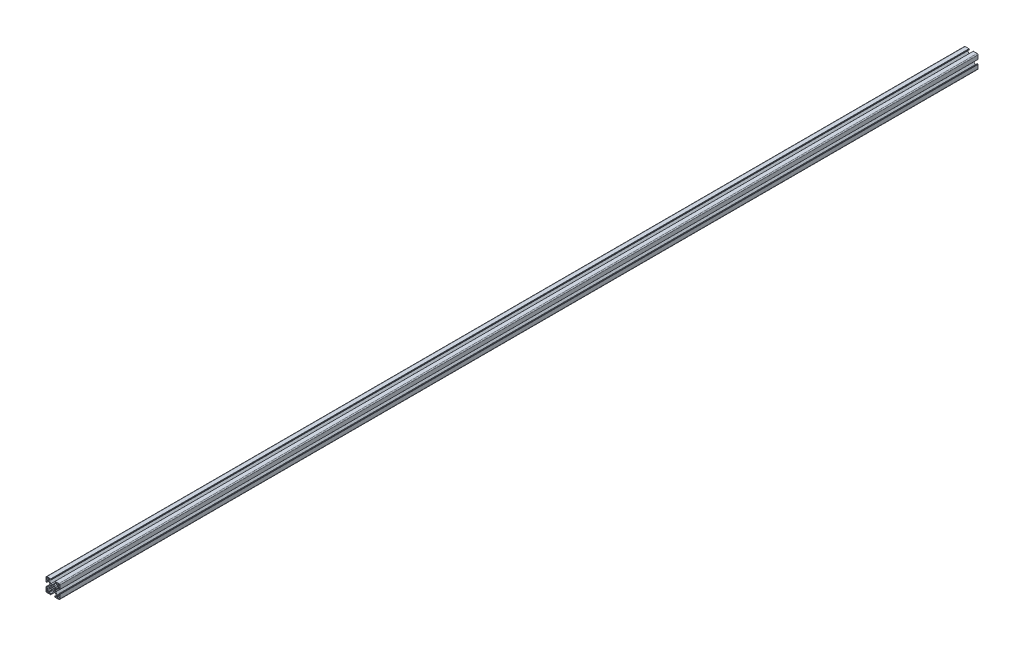
from build123d import *

# Parameters (mm, degrees)
SIGMA_PROFILE_DEPTH = 2000


with BuildPart() as part:
    # Sketch1 → Sigma Profile (new body)
    with BuildSketch(Plane.XY):
        with BuildLine():
            Line((96.56, 29.575148163), (97.459999946, 29.06))
            Line((97.459999946, 29.06), (100.764466193, 29.06))
            Line((100.764466193, 29.06), (104.810000327, 25.010000763))
            Line((104.810000327, 25.010000763), (104.810000327, 22.460001166))
            ThreePointArc((104.810000327, 22.460001166), (104.751421565, 22.318579525), (104.609999924, 22.260000763))
            Line((104.609999924, 22.260000763), (101.210000197, 22.260000763))
            ThreePointArc((101.210000197, 22.260000763), (100.785735989, 22.084264774), (100.61, 21.660000566))
            Line((100.61, 21.660000566), (100.61, 20.760000374))
            ThreePointArc((100.61, 20.760000374), (100.668578753, 20.618578753), (100.810000374, 20.56))
            Line((100.810000374, 20.56), (100.910000144, 20.56))
            ThreePointArc((100.910000144, 20.56), (101.05142109, 20.501421526), (101.109999564, 20.36000058))
            Line((101.109999564, 20.36000058), (101.109999564, 20.260000381))
            ThreePointArc((101.109999564, 20.260000381), (101.16857832, 20.118578755), (101.309999945, 20.06))
            Line((101.309999945, 20.06), (109.560000346, 20.06))
            ThreePointArc((109.560000346, 20.06), (110.974213664, 20.645786336), (111.56, 22.059999654))
            Line((111.56, 22.059999654), (111.56, 30.310000479))
            ThreePointArc((111.56, 30.310000479), (111.501421273, 30.451422036), (111.359999716, 30.510000763))
            Line((111.359999716, 30.510000763), (111.260000611, 30.510000763))
            ThreePointArc((111.260000611, 30.510000763), (111.118579054, 30.56857949), (111.060000327, 30.710001047))
            Line((111.060000327, 30.710001047), (111.060000327, 30.810000479))
            ThreePointArc((111.060000327, 30.810000479), (111.0014216, 30.951422036), (110.860000043, 31.010000763))
            Line((110.860000043, 31.010000763), (109.95999994, 31.010000763))
            ThreePointArc((109.95999994, 31.010000763), (109.535735606, 30.834264722), (109.359999564, 30.410000387))
            Line((109.359999564, 30.410000387), (109.359999564, 27.010000284))
            ThreePointArc((109.359999564, 27.010000284), (109.301420837, 26.868578727), (109.15999928, 26.81))
            Line((109.15999928, 26.81), (106.609999564, 26.81))
            Line((106.609999564, 26.81), (102.56446543, 30.855534134))
            Line((102.56446543, 30.855534134), (102.56446543, 34.160000381))
            Line((102.56446543, 34.160000381), (102.044852164, 35.06))
            Line((102.044852164, 35.06), (102.56446543, 35.959999619))
            Line((102.56446543, 35.959999619), (102.56446543, 39.264465866))
            Line((102.56446543, 39.264465866), (106.609999564, 43.31))
            Line((106.609999564, 43.31), (109.15999928, 43.31))
            ThreePointArc((109.15999928, 43.31), (109.301420837, 43.251421273), (109.359999564, 43.109999716))
            Line((109.359999564, 43.109999716), (109.359999564, 39.709999613))
            ThreePointArc((109.359999564, 39.709999613), (109.535735606, 39.285735278), (109.95999994, 39.109999237))
            Line((109.95999994, 39.109999237), (110.860000043, 39.109999237))
            ThreePointArc((110.860000043, 39.109999237), (111.0014216, 39.168577964), (111.060000327, 39.309999521))
            Line((111.060000327, 39.309999521), (111.060000327, 39.409998953))
            ThreePointArc((111.060000327, 39.409998953), (111.118579054, 39.55142051), (111.260000611, 39.609999237))
            Line((111.260000611, 39.609999237), (111.359999716, 39.609999237))
            ThreePointArc((111.359999716, 39.609999237), (111.501421273, 39.668577964), (111.56, 39.809999521))
            Line((111.56, 39.809999521), (111.56, 48.060000346))
            ThreePointArc((111.56, 48.060000346), (110.974213664, 49.474213664), (109.560000346, 50.06))
            Line((109.560000346, 50.06), (101.309999945, 50.06))
            ThreePointArc((101.309999945, 50.06), (101.16857832, 50.001421245), (101.109999564, 49.859999619))
            Line((101.109999564, 49.859999619), (101.109999564, 49.75999942))
            ThreePointArc((101.109999564, 49.75999942), (101.05142109, 49.618578474), (100.910000144, 49.56))
            Line((100.910000144, 49.56), (100.810000374, 49.56))
            ThreePointArc((100.810000374, 49.56), (100.668578753, 49.501421247), (100.61, 49.359999626))
            Line((100.61, 49.359999626), (100.61, 48.459999434))
            ThreePointArc((100.61, 48.459999434), (100.785735989, 48.035735226), (101.210000197, 47.859999237))
            Line((101.210000197, 47.859999237), (104.609999924, 47.859999237))
            ThreePointArc((104.609999924, 47.859999237), (104.751421565, 47.801420475), (104.810000327, 47.659998834))
            Line((104.810000327, 47.659998834), (104.810000327, 45.109999237))
            Line((104.810000327, 45.109999237), (100.764466193, 41.06))
            Line((100.764466193, 41.06), (97.459999946, 41.06))
            Line((97.459999946, 41.06), (96.56, 40.544851837))
            Line((96.56, 40.544851837), (95.660000054, 41.06))
            Line((95.660000054, 41.06), (92.355533807, 41.06))
            Line((92.355533807, 41.06), (88.309999673, 45.109999237))
            Line((88.309999673, 45.109999237), (88.309999673, 47.659998834))
            ThreePointArc((88.309999673, 47.659998834), (88.368578435, 47.801420475), (88.510000076, 47.859999237))
            Line((88.510000076, 47.859999237), (91.909999803, 47.859999237))
            ThreePointArc((91.909999803, 47.859999237), (92.334264011, 48.035735226), (92.51, 48.459999434))
            Line((92.51, 48.459999434), (92.51, 49.359999626))
            ThreePointArc((92.51, 49.359999626), (92.451421247, 49.501421247), (92.309999626, 49.56))
            Line((92.309999626, 49.56), (92.209999856, 49.56))
            ThreePointArc((92.209999856, 49.56), (92.06857891, 49.618578474), (92.010000436, 49.75999942))
            Line((92.010000436, 49.75999942), (92.010000436, 49.859999619))
            ThreePointArc((92.010000436, 49.859999619), (91.95142168, 50.001421245), (91.810000055, 50.06))
            Line((91.810000055, 50.06), (83.559999654, 50.06))
            ThreePointArc((83.559999654, 50.06), (82.145786336, 49.474213664), (81.56, 48.060000346))
            Line((81.56, 48.060000346), (81.56, 39.809999521))
            ThreePointArc((81.56, 39.809999521), (81.618578727, 39.668577964), (81.760000284, 39.609999237))
            Line((81.760000284, 39.609999237), (81.859999389, 39.609999237))
            ThreePointArc((81.859999389, 39.609999237), (82.001420946, 39.55142051), (82.059999673, 39.409998953))
            Line((82.059999673, 39.409998953), (82.059999673, 39.309999521))
            ThreePointArc((82.059999673, 39.309999521), (82.1185784, 39.168577964), (82.259999957, 39.109999237))
            Line((82.259999957, 39.109999237), (83.16000006, 39.109999237))
            ThreePointArc((83.16000006, 39.109999237), (83.584264394, 39.285735278), (83.760000436, 39.709999613))
            Line((83.760000436, 39.709999613), (83.760000436, 43.109999716))
            ThreePointArc((83.760000436, 43.109999716), (83.818579163, 43.251421273), (83.96000072, 43.31))
            Line((83.96000072, 43.31), (86.510000436, 43.31))
            Line((86.510000436, 43.31), (90.55553457, 39.264465866))
            Line((90.55553457, 39.264465866), (90.55553457, 35.959999619))
            Line((90.55553457, 35.959999619), (91.075147836, 35.06))
            Line((91.075147836, 35.06), (90.55553457, 34.160000381))
            Line((90.55553457, 34.160000381), (90.55553457, 30.855534134))
            Line((90.55553457, 30.855534134), (86.510000436, 26.81))
            Line((86.510000436, 26.81), (83.96000072, 26.81))
            ThreePointArc((83.96000072, 26.81), (83.818579163, 26.868578727), (83.760000436, 27.010000284))
            Line((83.760000436, 27.010000284), (83.760000436, 30.410000387))
            ThreePointArc((83.760000436, 30.410000387), (83.584264394, 30.834264722), (83.16000006, 31.010000763))
            Line((83.16000006, 31.010000763), (82.259999957, 31.010000763))
            ThreePointArc((82.259999957, 31.010000763), (82.1185784, 30.951422036), (82.059999673, 30.810000479))
            Line((82.059999673, 30.810000479), (82.059999673, 30.710001047))
            ThreePointArc((82.059999673, 30.710001047), (82.001420946, 30.56857949), (81.859999389, 30.510000763))
            Line((81.859999389, 30.510000763), (81.760000284, 30.510000763))
            ThreePointArc((81.760000284, 30.510000763), (81.618578727, 30.451422036), (81.56, 30.310000479))
            Line((81.56, 30.310000479), (81.56, 22.059999654))
            ThreePointArc((81.56, 22.059999654), (82.145786336, 20.645786336), (83.559999654, 20.06))
            Line((83.559999654, 20.06), (91.810000055, 20.06))
            ThreePointArc((91.810000055, 20.06), (91.95142168, 20.118578755), (92.010000436, 20.260000381))
            Line((92.010000436, 20.260000381), (92.010000436, 20.36000058))
            ThreePointArc((92.010000436, 20.36000058), (92.06857891, 20.501421526), (92.209999856, 20.56))
            Line((92.209999856, 20.56), (92.309999626, 20.56))
            ThreePointArc((92.309999626, 20.56), (92.451421247, 20.618578753), (92.51, 20.760000374))
            Line((92.51, 20.760000374), (92.51, 21.660000566))
            ThreePointArc((92.51, 21.660000566), (92.334264011, 22.084264774), (91.909999803, 22.260000763))
            Line((91.909999803, 22.260000763), (88.510000076, 22.260000763))
            ThreePointArc((88.510000076, 22.260000763), (88.368578435, 22.318579525), (88.309999673, 22.460001166))
            Line((88.309999673, 22.460001166), (88.309999673, 25.010000763))
            Line((88.309999673, 25.010000763), (92.355533807, 29.06))
            Line((92.355533807, 29.06), (95.660000054, 29.06))
            Line((95.660000054, 29.06), (96.56, 29.575148163))
        make_face()
        with BuildLine():
            Line((109.26000109, 48.760000398), (107.060000327, 48.760000398))
            ThreePointArc((107.060000327, 48.760000398), (106.352893543, 48.467107182), (106.060000327, 47.760000398))
            Line((106.060000327, 47.760000398), (106.060000327, 45.559999635))
            ThreePointArc((106.060000327, 45.559999635), (106.352893543, 44.852892851), (107.060000327, 44.559999635))
            Line((107.060000327, 44.559999635), (109.26000109, 44.559999635))
            ThreePointArc((109.26000109, 44.559999635), (109.967107874, 44.852892851), (110.26000109, 45.559999635))
            Line((110.26000109, 45.559999635), (110.26000109, 47.760000398))
            ThreePointArc((110.26000109, 47.760000398), (109.967107874, 48.467107182), (109.26000109, 48.760000398))
        make_face(mode=Mode.SUBTRACT)
        with BuildLine():
            Line((94.959870476, 38.340561767), (93.424070588, 39.578400903))
            ThreePointArc((93.424070588, 39.578400903), (92.678997741, 38.957155561), (92.054663108, 38.214669473))
            Line((92.054663108, 38.214669473), (93.279438268, 36.660129597))
            ThreePointArc((93.279438268, 36.660129597), (92.91, 35.06), (93.279438268, 33.459870403))
            Line((93.279438268, 33.459870403), (92.054663108, 31.905330527))
            ThreePointArc((92.054663108, 31.905330527), (92.678997741, 31.162844439), (93.424070588, 30.541599097))
            Line((93.424070588, 30.541599097), (94.959870476, 31.779438233))
            ThreePointArc((94.959870476, 31.779438233), (96.56, 31.41), (98.160129524, 31.779438233))
            Line((98.160129524, 31.779438233), (99.695929412, 30.541599097))
            ThreePointArc((99.695929412, 30.541599097), (100.441002259, 31.162844439), (101.065336892, 31.905330527))
            Line((101.065336892, 31.905330527), (99.840561732, 33.459870403))
            ThreePointArc((99.840561732, 33.459870403), (100.21, 35.06), (99.840561732, 36.660129597))
            Line((99.840561732, 36.660129597), (101.065336892, 38.214669473))
            ThreePointArc((101.065336892, 38.214669473), (100.441002259, 38.957155561), (99.695929412, 39.578400903))
            Line((99.695929412, 39.578400903), (98.160129524, 38.340561767))
            ThreePointArc((98.160129524, 38.340561767), (96.56, 38.71), (94.959870476, 38.340561767))
        make_face(mode=Mode.SUBTRACT)
        with BuildLine():
            Line((83.85999891, 21.359999602), (86.059999673, 21.359999602))
            ThreePointArc((86.059999673, 21.359999602), (86.767106457, 21.652892818), (87.059999673, 22.359999602))
            Line((87.059999673, 22.359999602), (87.059999673, 24.560000365))
            ThreePointArc((87.059999673, 24.560000365), (86.767106457, 25.267107149), (86.059999673, 25.560000365))
            Line((86.059999673, 25.560000365), (83.85999891, 25.560000365))
            ThreePointArc((83.85999891, 25.560000365), (83.152892126, 25.267107149), (82.85999891, 24.560000365))
            Line((82.85999891, 24.560000365), (82.85999891, 22.359999602))
            ThreePointArc((82.85999891, 22.359999602), (83.152892126, 21.652892818), (83.85999891, 21.359999602))
        make_face(mode=Mode.SUBTRACT)
        with BuildLine():
            Line((110.26000109, 22.359999602), (110.26000109, 24.560000365))
            ThreePointArc((110.26000109, 24.560000365), (109.967107874, 25.267107149), (109.26000109, 25.560000365))
            Line((109.26000109, 25.560000365), (107.060000327, 25.560000365))
            ThreePointArc((107.060000327, 25.560000365), (106.352893543, 25.267107149), (106.060000327, 24.560000365))
            Line((106.060000327, 24.560000365), (106.060000327, 22.359999602))
            ThreePointArc((106.060000327, 22.359999602), (106.352893543, 21.652892818), (107.060000327, 21.359999602))
            Line((107.060000327, 21.359999602), (109.26000109, 21.359999602))
            ThreePointArc((109.26000109, 21.359999602), (109.967107874, 21.652892818), (110.26000109, 22.359999602))
        make_face(mode=Mode.SUBTRACT)
        with BuildLine():
            Line((86.059999673, 48.760000398), (83.85999891, 48.760000398))
            ThreePointArc((83.85999891, 48.760000398), (83.152892126, 48.467107182), (82.85999891, 47.760000398))
            Line((82.85999891, 47.760000398), (82.85999891, 45.559999635))
            ThreePointArc((82.85999891, 45.559999635), (83.152892126, 44.852892851), (83.85999891, 44.559999635))
            Line((83.85999891, 44.559999635), (86.059999673, 44.559999635))
            ThreePointArc((86.059999673, 44.559999635), (86.767106457, 44.852892851), (87.059999673, 45.559999635))
            Line((87.059999673, 45.559999635), (87.059999673, 47.760000398))
            ThreePointArc((87.059999673, 47.760000398), (86.767106457, 48.467107182), (86.059999673, 48.760000398))
        make_face(mode=Mode.SUBTRACT)
    extrude(amount=SIGMA_PROFILE_DEPTH)


solid = part.part
